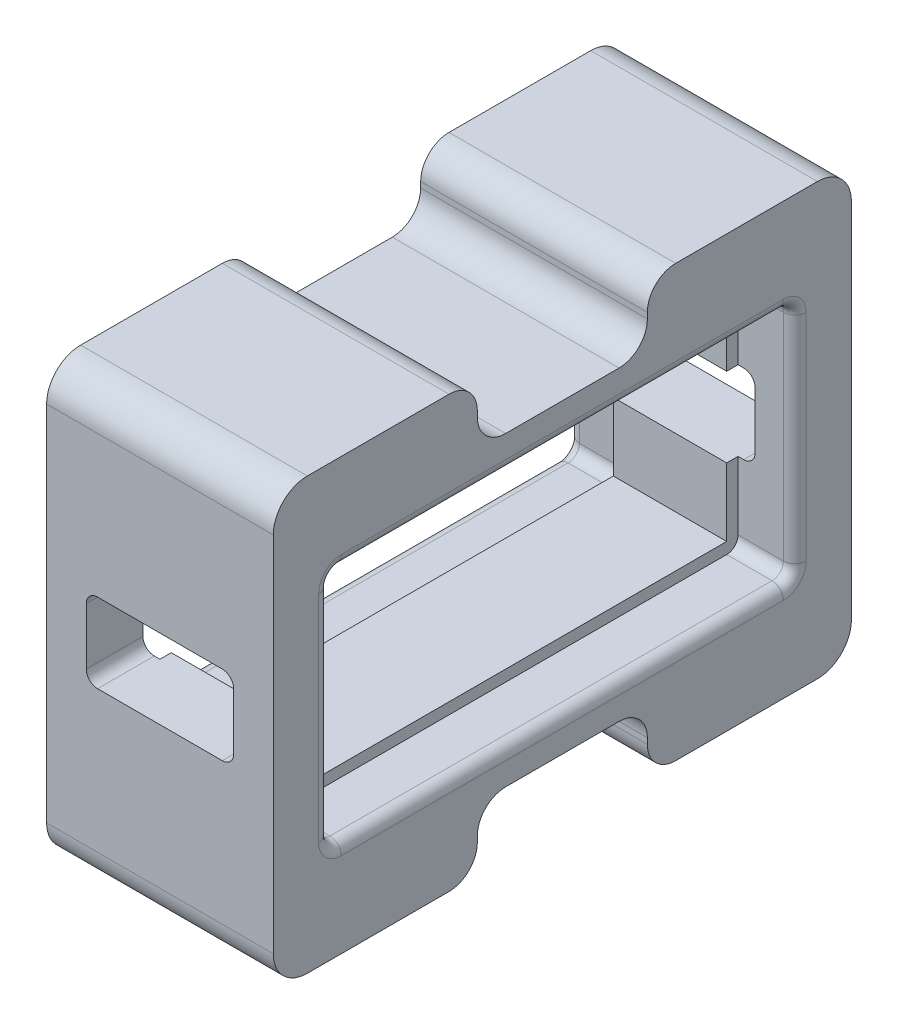
from build123d import *

# Parameters (mm, degrees)
SKETCH1_W                   = 51
SKETCH1_H                   = 38
SKETCH1_W_2                 = 41
SKETCH1_H_2                 = 21
MAIN_BODY_DEPTH             = 10
SKETCH2_W                   = 41
SKETCH2_H                   = 21
SKETCH2_W_2                 = 39
SKETCH2_H_2                 = 19
MID_SERVO_GAP_DEPTH         = 5
EDGE_CONTOURING_R           = 1
SKETCH3_W                   = 13
SKETCH3_H                   = 7
AIRWAY_DEPTH                = 52
SKETCH4_W                   = 15
SKETCH4_H                   = 5.5
CLEARANCE_CABLES_DEPTH      = 21
CONTOURING_OUTER_R          = 3
CONTOURING_AIRWAY_R         = 1
CONTOURING_INNER_R          = 2.5
CLEARANCE_SERVO_INSERTION_R = 1


with BuildPart() as part:
    # Sketch1 → Main Body (new body, symmetric)
    with BuildSketch(Plane(origin=(0, 0, 0), x_dir=(0, 0, -1), z_dir=(1, 0, 0))):
        Rectangle(SKETCH1_W, SKETCH1_H)
        Rectangle(SKETCH1_W_2, SKETCH1_H_2, mode=Mode.SUBTRACT)
    extrude(amount=MAIN_BODY_DEPTH, both=True)

    # Sketch2 → Mid Servo Gap (add, symmetric)
    with BuildSketch(Plane(origin=(0, 0, 0), x_dir=(0, 0, -1), z_dir=(1, 0, 0))):
        Rectangle(SKETCH2_W, SKETCH2_H)
        Rectangle(SKETCH2_W_2, SKETCH2_H_2, mode=Mode.SUBTRACT)
    extrude(amount=MID_SERVO_GAP_DEPTH, both=True)

    # Edge Contouring
    edge_contouring_edges = [part.edges().sort_by_distance(p)[0] for p in [
        (7.5, 10.5, 20.5),
        (7.5, -10.5, 20.5),
        (7.5, -10.5, -20.5),
        (7.5, 10.5, -20.5),
        (-7.5, 10.5, -20.5),
        (-7.5, 10.5, 20.5),
        (-7.5, -10.5, -20.5),
        (-7.5, -10.5, 20.5),
        (0, 9.5, 19.5),
        (0, -9.5, 19.5),
        (0, 9.5, -19.5),
    ]]
    fillet(edge_contouring_edges, radius=EDGE_CONTOURING_R)

    # Sketch3 → Airway (cut, through all)
    with BuildSketch(Plane.XY.offset(25.5)):
        Rectangle(SKETCH3_W, SKETCH3_H)
    extrude(amount=-AIRWAY_DEPTH, mode=Mode.SUBTRACT)

    # Sketch4 → Clearance - Cables (cut, through all)
    with BuildSketch(Plane(origin=(10, 0, 0), x_dir=(0, 0, -1), z_dir=(1, 0, 0))):
        with Locations((0, 16.25)):
            Rectangle(SKETCH4_W, SKETCH4_H)
        with Locations((0, -16.25)):
            Rectangle(SKETCH4_W, SKETCH4_H)
    extrude(amount=-CLEARANCE_CABLES_DEPTH, mode=Mode.SUBTRACT)

    # Contouring - Outer
    contouring_outer_edges = [part.edges().sort_by_distance(p)[0] for p in [
        (0, 19, 25.5),
        (0, 19, -25.5),
        (0, -19, -25.5),
        (0, -19, 25.5),
    ]]
    fillet(contouring_outer_edges, radius=CONTOURING_OUTER_R)

    # Contouring - Airway
    contouring_airway_edges = [part.edges().sort_by_distance(p)[0] for p in [
        (-6.5, -3.5, 23),
        (6.5, 3.5, 23),
        (-6.5, 3.5, 23),
        (6.5, -3.5, 23),
        (-6.5, -3.5, -23),
        (-6.5, 3.5, -23),
        (6.5, 3.5, -23),
        (6.5, -3.5, -23),
    ]]
    fillet(contouring_airway_edges, radius=CONTOURING_AIRWAY_R)

    # Contouring - Inner
    contouring_inner_edges = [part.edges().sort_by_distance(p)[0] for p in [
        (0, 13.5, 7.5),
        (0, 19, 7.5),
        (0, 19, -7.5),
        (0, 13.5, -7.5),
        (0, -19, -7.5),
        (0, -19, 7.5),
        (0, -13.5, 7.5),
        (0, -13.5, -7.5),
    ]]
    fillet(contouring_inner_edges, radius=CONTOURING_INNER_R)

    # Clearance - Servo Insertion
    clearance_servo_insertion_edges = [part.edges().sort_by_distance(p)[0] for p in [
        (-10, -10.5, 0),
        (-10, 0, -20.5),
        (-10, 0, 20.5),
        (10, 0, -20.5),
        (10, 10.5, 0),
        (-10, 10.5, 0),
        (10, 0, 20.5),
        (10, -10.5, 0),
        (-10, -10.207106781, -20.207106781),
        (-10, -10.207106781, 20.207106781),
        (10, 10.207106781, -20.207106781),
        (-10, 10.207106781, -20.207106781),
        (-10, 10.207106781, 20.207106781),
        (10, 10.207106781, 20.207106781),
        (10, -10.207106781, 20.207106781),
        (10, -10.207106781, -20.207106781),
    ]]
    fillet(clearance_servo_insertion_edges, radius=CLEARANCE_SERVO_INSERTION_R)


solid = part.part
